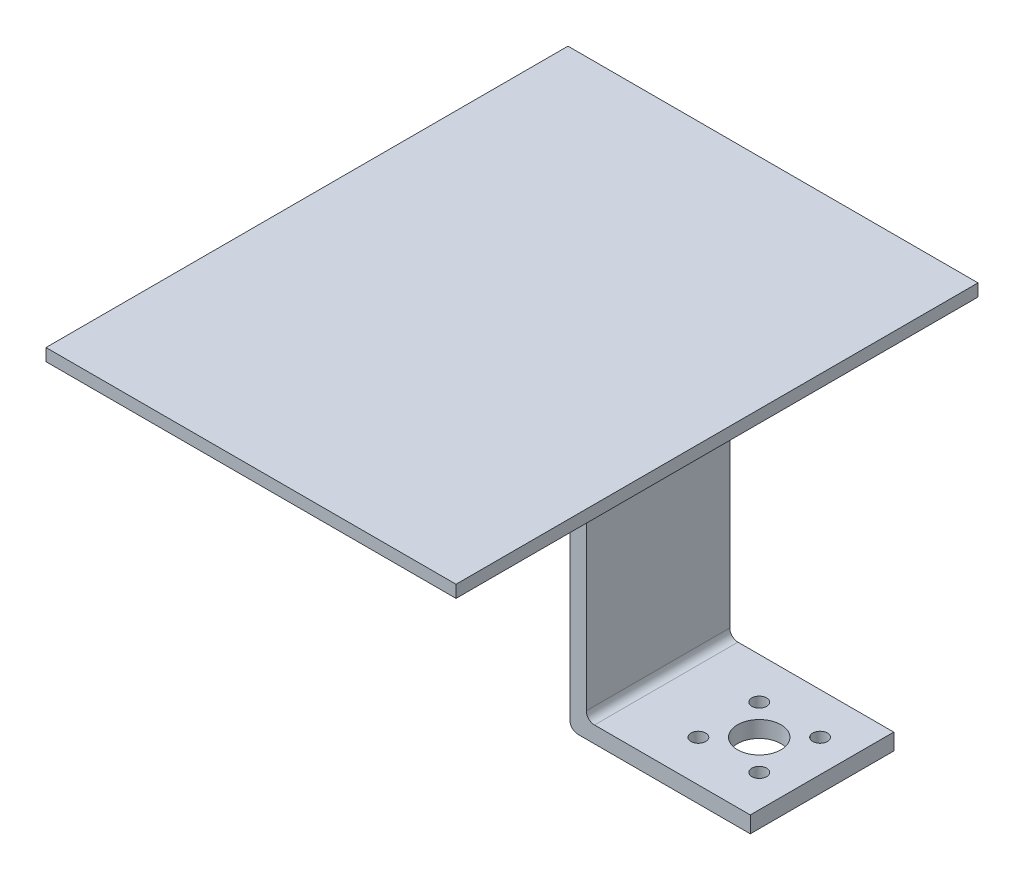
from build123d import *

# Parameters (mm, degrees)
CROQUIS1_W              = 100
CROQUIS1_H              = 127.304752994
SALIENTE_EXTRUIR1_DEPTH = 3
CROQUIS2_W              = 4
CROQUIS2_H              = 34.992450208
SALIENTE_EXTRUIR2_DEPTH = 60
CROQUIS4_W              = 34.992450208
CROQUIS4_H              = 4
SALIENTE_EXTRUIR3_DEPTH = 40
CHAFL_N1_SIZE           = 10
REDONDEO1_R             = 2
CROQUIS5_R              = 5.3
CROQUIS5_R_2            = 1.8
CORTAR_EXTRUIR2_DEPTH   = 40


with BuildPart() as part:
    # Croquis1 → Saliente-Extruir1 (new body)
    with BuildSketch(Plane(origin=(0, 0, 0), x_dir=(1, 0, 0), z_dir=(0, 1, 0))):
        Rectangle(CROQUIS1_W, CROQUIS1_H)
    extrude(amount=SALIENTE_EXTRUIR1_DEPTH)

    # Croquis2 → Saliente-Extruir2 (add)
    with BuildSketch(Plane.XZ):
        with Locations((33.610839978, 0)):
            Rectangle(CROQUIS2_W, CROQUIS2_H)
    extrude(amount=SALIENTE_EXTRUIR2_DEPTH)

    # Croquis4 → Saliente-Extruir3 (add)
    with BuildSketch(Plane(origin=(35.610839978, 0, 0), x_dir=(0, 0, -1), z_dir=(1, 0, 0))):
        with Locations((0, -58)):
            Rectangle(CROQUIS4_W, CROQUIS4_H)
    extrude(amount=SALIENTE_EXTRUIR3_DEPTH)

    # Chaflán1
    chafl_n1_edges = [part.edges().sort_by_distance(p)[0] for p in [
        (31.610839978, 0, 0),
    ]]
    chamfer(chafl_n1_edges, length=CHAFL_N1_SIZE)

    # Redondeo1
    redondeo1_edges = [part.edges().sort_by_distance(p)[0] for p in [
        (31.610839978, -60, 0),
        (35.610839978, -56, 0),
    ]]
    fillet(redondeo1_edges, radius=REDONDEO1_R)

    # Croquis5 → Cortar-Extruir2 (cut)
    with BuildSketch(Plane.XZ.offset(60)):
        with Locations((60.298029847, 0)):
            Circle(CROQUIS5_R)
        with Locations((67.72265105, -7.424621202)):
            Circle(CROQUIS5_R_2)
        with Locations((52.873408645, -7.424621202)):
            Circle(CROQUIS5_R_2)
        with Locations((52.873408645, 7.424621202)):
            Circle(CROQUIS5_R_2)
        with Locations((67.72265105, 7.424621202)):
            Circle(CROQUIS5_R_2)
    extrude(amount=-CORTAR_EXTRUIR2_DEPTH, mode=Mode.SUBTRACT)


solid = part.part
